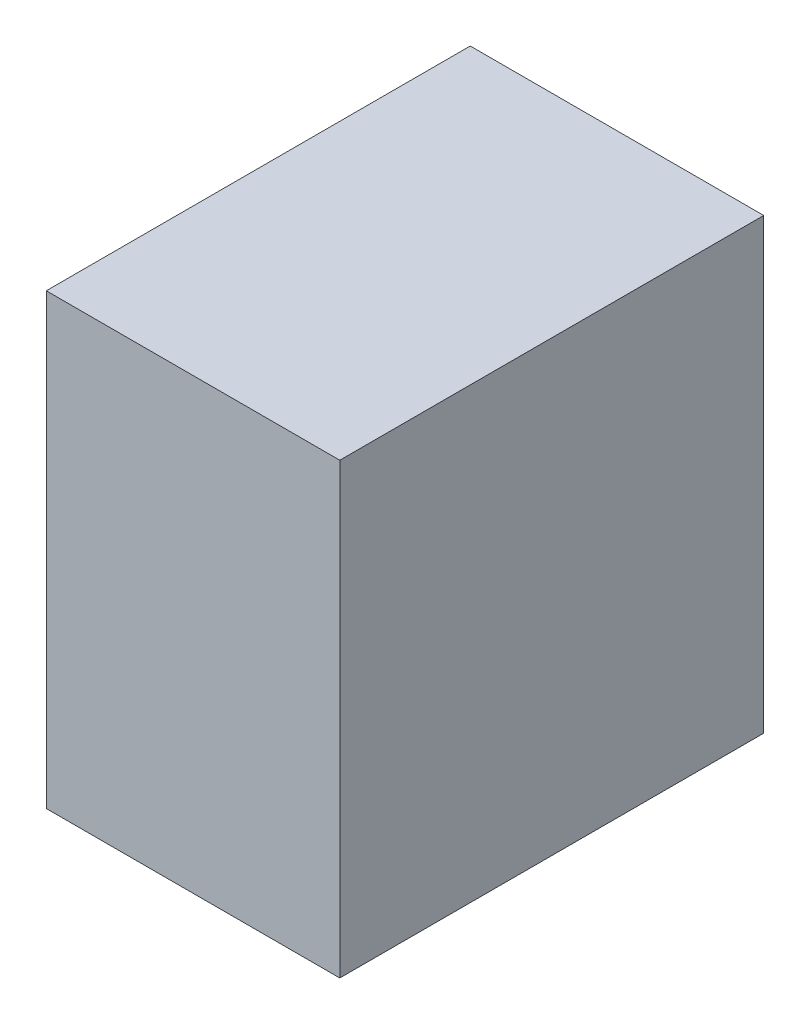
from build123d import *

# Parameters (mm, degrees)
ESQUISSE1_W        = 36
ESQUISSE1_H        = 52
BOSS_EXTRU_1_DEPTH = 55


with BuildPart() as part:
    # Esquisse1 → Boss.-Extru.1 (new body)
    with BuildSketch(Plane(origin=(0, 0, 0), x_dir=(1, 0, 0), z_dir=(0, 1, 0))):
        with Locations((-67.484794443, -1.899378251)):
            Rectangle(ESQUISSE1_W, ESQUISSE1_H)
    extrude(amount=BOSS_EXTRU_1_DEPTH)


solid = part.part
